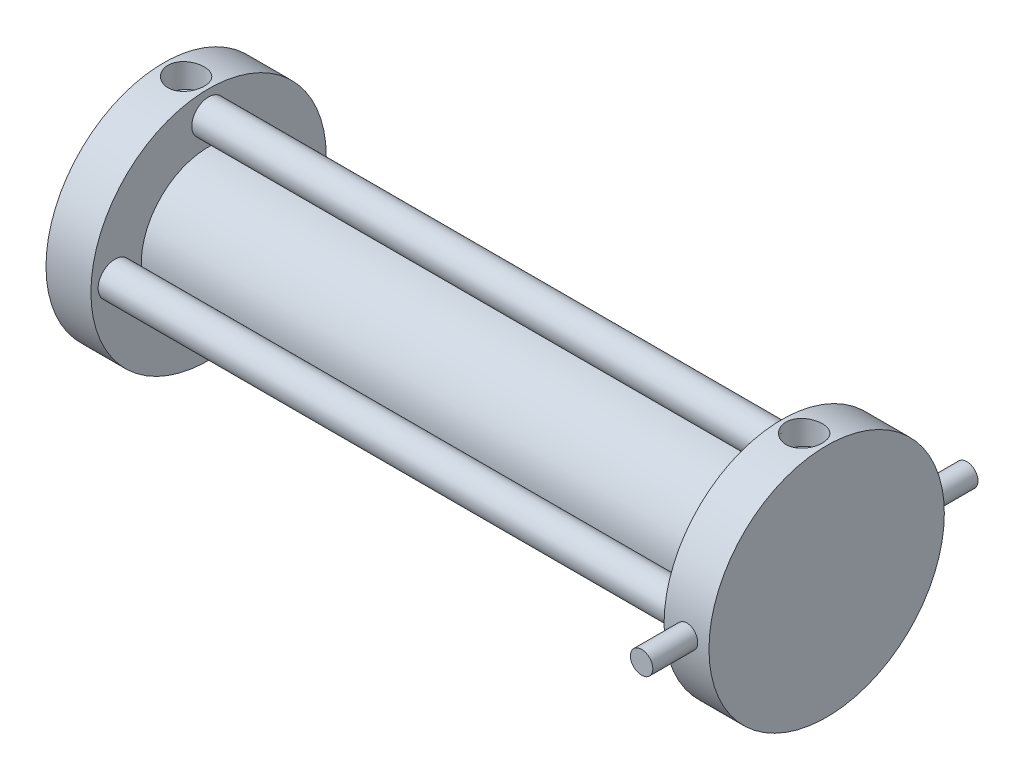
from build123d import *

# Parameters (mm, degrees)
SKETCH1_R                         = 33.274
BOSS_EXTRUDE1_DEPTH               = 12.7
SKETCH2_R                         = 19.05
BOSS_EXTRUDE2_DEPTH               = 162.052
SKETCH3_R                         = 33.274
BOSS_EXTRUDE3_DEPTH               = 12.7
SKETCH4_R                         = 4.7625
BOSS_EXTRUDE4_DEPTH               = 174.752
BOSS_EXTRUDE5_START               = -0.151825
SKETCH5_R                         = 3.175
BOSS_EXTRUDE5_DEPTH               = 12.851825
BOSS_EXTRUDE6_START               = -0.151825
SKETCH6_R                         = 3.175
BOSS_EXTRUDE6_DEPTH               = 12.851825
F_1_8_NPT_TAPPED_HOLE1_AT_2_COUNT = 2
F_1_8_NPT_TAPPED_HOLE1_AT_2_PITCH = 174.752


with BuildPart() as part:
    # Sketch1 → Boss-Extrude1 (new body)
    with BuildSketch(Plane(origin=(0, 0, 0), x_dir=(0, 0, -1), z_dir=(1, 0, 0))):
        Circle(SKETCH1_R)
    extrude(amount=BOSS_EXTRUDE1_DEPTH)

    # Sketch2 → Boss-Extrude2 (add)
    with BuildSketch(Plane(origin=(12.7, 0, 0), x_dir=(0, 0, -1), z_dir=(1, 0, 0))):
        Circle(SKETCH2_R)
    extrude(amount=BOSS_EXTRUDE2_DEPTH)

    # Sketch3 → Boss-Extrude3 (add)
    with BuildSketch(Plane(origin=(174.752, 0, 0), x_dir=(0, 0, -1), z_dir=(1, 0, 0))):
        Circle(SKETCH3_R)
    extrude(amount=BOSS_EXTRUDE3_DEPTH)

    # Sketch4 → Boss-Extrude4 (add)
    with BuildSketch(Plane(origin=(187.452, 0, 0), x_dir=(0, 0, -1), z_dir=(1, 0, 0))):
        with Locations((26.4795, 0)):
            Circle(SKETCH4_R)
        with Locations((0, -26.4795)):
            Circle(SKETCH4_R)
        with Locations((-26.4795, 0)):
            Circle(SKETCH4_R)
        with Locations((0, 26.4795)):
            Circle(SKETCH4_R)
    extrude(amount=-BOSS_EXTRUDE4_DEPTH)

    # Sketch5 → Boss-Extrude5 (add)
    with BuildSketch(Plane(origin=(0, 0, -33.274), x_dir=(-1, 0, 0), z_dir=(0, 0, -1)).offset(BOSS_EXTRUDE5_START)):
        with Locations((-181.102, 0)):
            Circle(SKETCH5_R)
    extrude(amount=BOSS_EXTRUDE5_DEPTH)

    # Sketch6 → Boss-Extrude6 (add)
    with BuildSketch(Plane.XY.offset(33.274).offset(BOSS_EXTRUDE6_START)):
        with Locations((181.102, 0)):
            Circle(SKETCH6_R)
    extrude(amount=BOSS_EXTRUDE6_DEPTH)

    # Sketch8 → 1_8 NPT Tapped Hole1 (revolve, cut)
    with BuildSketch(Plane(origin=(181.102, 33.274, 0), x_dir=(0, 0, 1), z_dir=(1, 0, 0))):
        Polygon((0, 0), (0, 14.217468714), (4.2164, 11.684), (4.2164, 6.858), (4.936181096, 6.858), (5.1415188, 0), align=None)
    f_1_8_npt_tapped_hole1 = revolve(axis=Axis((181.102, 39.624, 0), (0, -1, 0)), mode=Mode.SUBTRACT)

    # 1_8 NPT Tapped Hole1 at 2: 1_8 NPT Tapped Hole1 ×2
    with Locations(*[(-i * F_1_8_NPT_TAPPED_HOLE1_AT_2_PITCH, 0, 0) for i in range(1, F_1_8_NPT_TAPPED_HOLE1_AT_2_COUNT)]):
        add(f_1_8_npt_tapped_hole1, mode=Mode.SUBTRACT)


solid = part.part
